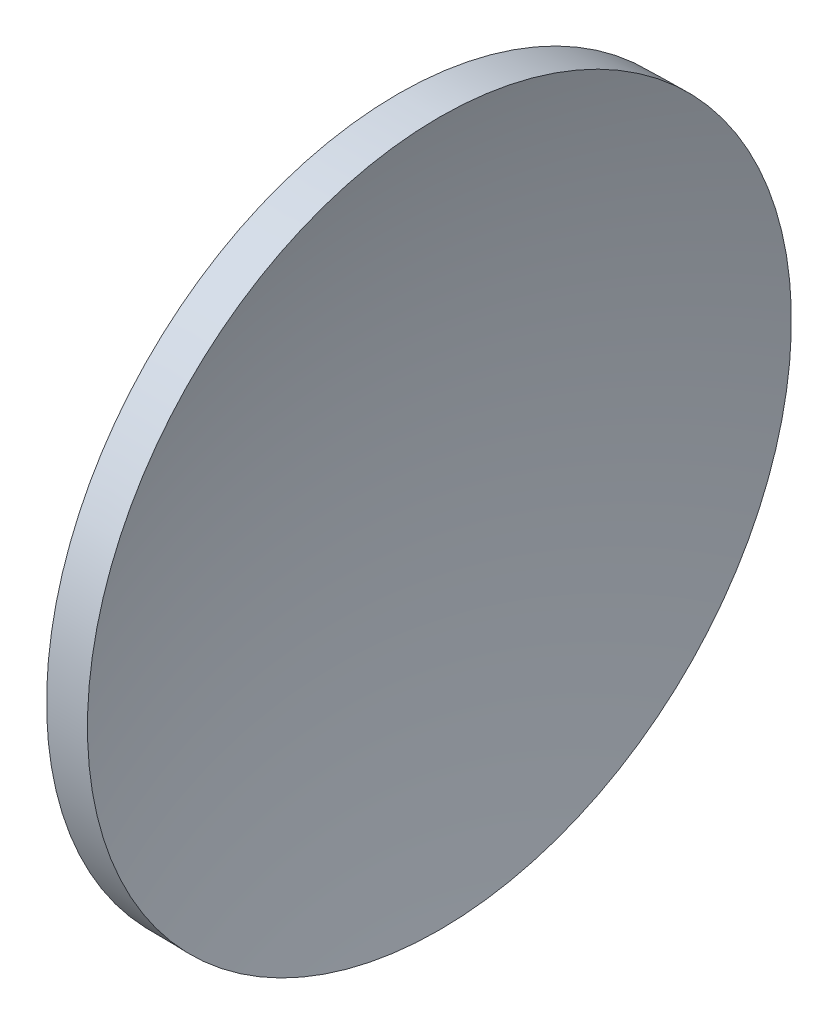
from build123d import *


with BuildPart() as part:
    # 草图1 → 旋转1 (revolve)
    with BuildSketch(Plane.XY):
        with BuildLine():
            Line((125.480639547, 77.722759658), (126.955628497, 77.743891611))
            ThreePointArc((126.955628497, 77.743891611), (125.542172717, 71.551114136), (125.067486245, 65.216840471))
            Line((125.067486245, 65.216840471), (122.567486245, 65.216840471))
            ThreePointArc((122.567486245, 65.216840471), (123.305394873, 71.637208001), (125.480639547, 77.722759658))
        make_face()
    revolve(axis=Axis((115.944491298, 65.216840471, 0), (1, 0, 0)))


solid = part.part
